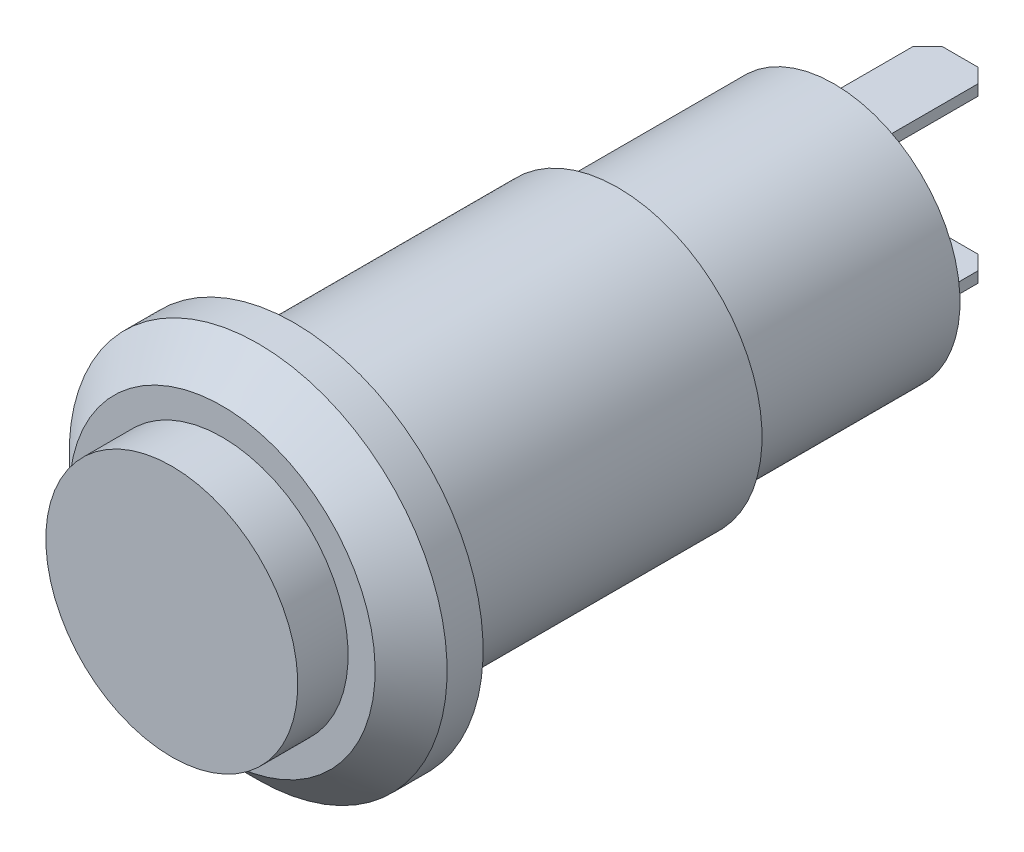
from build123d import *

# Parameters (mm, degrees)
SKETCH_6_W      = 1.8
SKETCH_6_H      = 0.3
EXTRUDE_2_DEPTH = 3.5
CHAMFER_2_SIZE  = 1
CHAMFER_3_SIZE  = 0.4


with BuildPart() as part:
    # 草图1 → 旋转2 (revolve)
    with BuildSketch(Plane(origin=(0, 0, 0), x_dir=(0, 0, -1), z_dir=(1, 0, 0))):
        Polygon((-18.4, 0), (-18.4, 3.5), (-17, 3.5), (-17, 5.25), (-15, 5.25), (-15, 4), (-6, 4), (-6, 3.5), (0, 3.5), (0, 0), align=None)
    revolve(axis=Axis((0, 0, 0), (0, 0, 1)))

    # 草图6 → 凸台-拉伸2 (add)
    with BuildSketch(Plane(origin=(0, 0, 0), x_dir=(-1, 0, 0), z_dir=(0, 0, -1))):
        with Locations((0, 2.25)):
            Rectangle(SKETCH_6_W, SKETCH_6_H)
        with Locations((0, -2.25)):
            Rectangle(SKETCH_6_W, SKETCH_6_H)
    extrude(amount=EXTRUDE_2_DEPTH)

    # 倒角2
    chamfer_2_edges = [part.edges().sort_by_distance(p)[0] for p in [
        (0, -5.25, 17),
    ]]
    chamfer(chamfer_2_edges, length=CHAMFER_2_SIZE)

    # 倒角3
    chamfer_3_edges = [part.edges().sort_by_distance(p)[0] for p in [
        (-0.9, 2.25, -3.5),
        (0.9, 2.25, -3.5),
        (-0.9, -2.25, -3.5),
        (0.9, -2.25, -3.5),
    ]]
    chamfer(chamfer_3_edges, length=CHAMFER_3_SIZE)


solid = part.part
